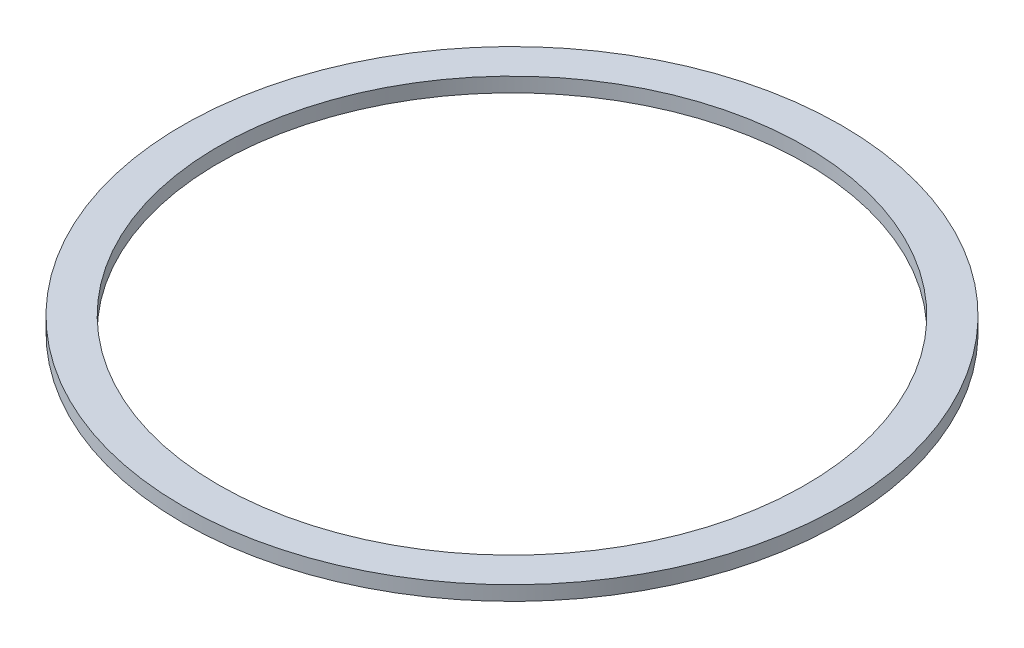
from build123d import *

# Parameters (mm, degrees)
SKETCH1_R           = 28.8925
SKETCH1_R_2         = 25.7175
BOSS_EXTRUDE1_DEPTH = 1.27


with BuildPart() as part:
    # Sketch1 → Boss-Extrude1 (new body)
    with BuildSketch(Plane(origin=(0, 0, 0), x_dir=(1, 0, 0), z_dir=(0, 1, 0))):
        Circle(SKETCH1_R)
        Circle(SKETCH1_R_2, mode=Mode.SUBTRACT)
    extrude(amount=BOSS_EXTRUDE1_DEPTH)


solid = part.part
